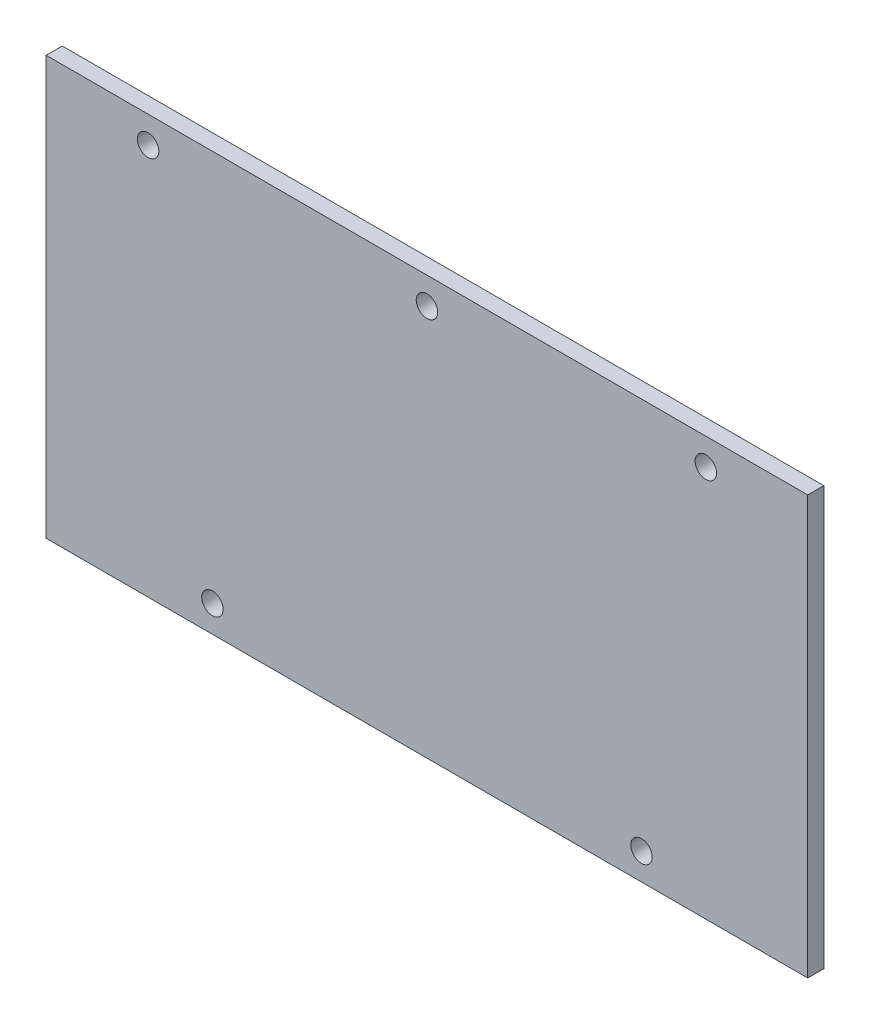
from build123d import *

# Parameters (mm, degrees)
SKETCH_1_W          = 71
SKETCH_1_H          = 39
EXTRUDE_1_DEPTH     = 1.5
SKETCH_2_R          = 1
CUT_EXTRUDE_1_DEPTH = 2.5


with BuildPart() as part:
    # Эскиз1 → Бобышка-Вытянуть1 (new body)
    with BuildSketch(Plane.XY):
        Rectangle(SKETCH_1_W, SKETCH_1_H)
    extrude(amount=EXTRUDE_1_DEPTH)

    # Эскиз2 → Вырез-Вытянуть1 (cut, through all)
    with BuildSketch(Plane.XY.offset(1.5)):
        with Locations((26, 17)):
            Circle(SKETCH_2_R)
        with Locations((-26, 17)):
            Circle(SKETCH_2_R)
        with Locations((0, 17)):
            Circle(SKETCH_2_R)
        with Locations((20, -17)):
            Circle(SKETCH_2_R)
        with Locations((-20, -17)):
            Circle(SKETCH_2_R)
    extrude(amount=-CUT_EXTRUDE_1_DEPTH, mode=Mode.SUBTRACT)


solid = part.part
